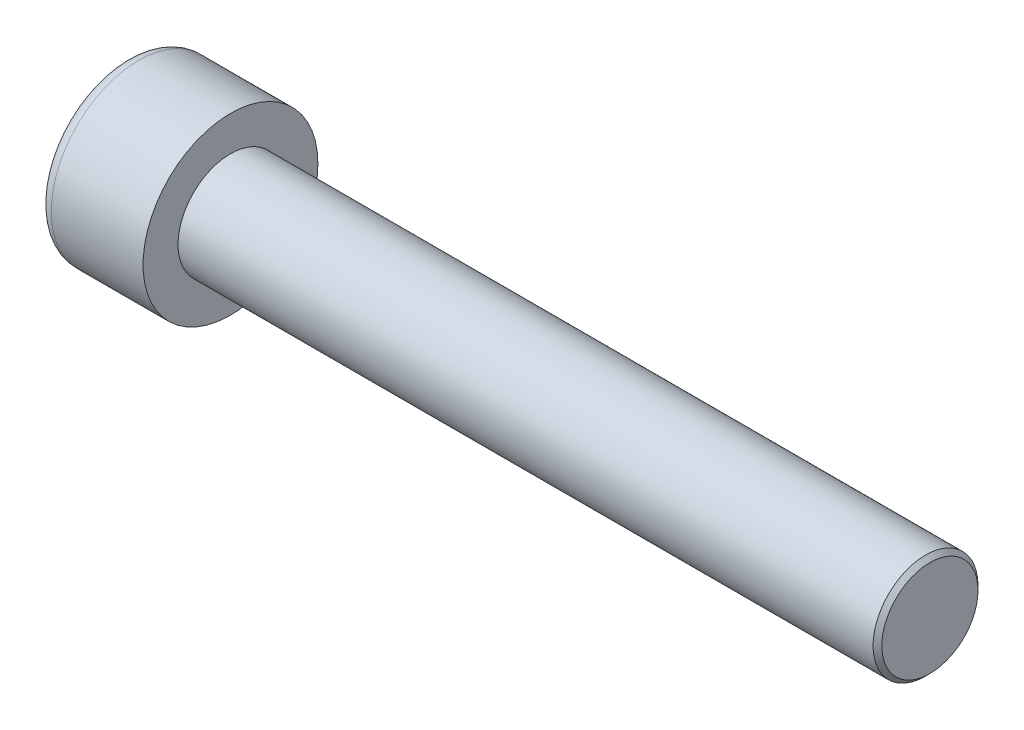
from build123d import *

# Parameters (mm, degrees)
SKETCH1_R           = 5
BASEHEAD_DEPTH      = 6
SKETCH2_R           = 3
BASEBODY_DEPTH      = 40
HEXAGONSOCKET_DEPTH = 3
TOPFILLET_R         = 0.75
CHAMFER1_SIZE       = 0.25


with BuildPart() as part:
    # Sketch1 → BaseHead (new body)
    with BuildSketch(Plane(origin=(0, 0, 0), x_dir=(0, 0, -1), z_dir=(1, 0, 0))):
        Circle(SKETCH1_R)
    extrude(amount=BASEHEAD_DEPTH)

    # Sketch2 → BaseBody (add)
    with BuildSketch(Plane(origin=(6, 0, 0), x_dir=(0, 0, -1), z_dir=(1, 0, 0))):
        Circle(SKETCH2_R)
    extrude(amount=BASEBODY_DEPTH)

    # Sketch3 → HexagonSocket (cut)
    with BuildSketch(Plane(origin=(0, 0, 0), x_dir=(0, 0, -1), z_dir=(1, 0, 0))):
        Polygon((2.886751346, 0), (1.443375673, 2.5), (-1.443375673, 2.5), (-2.886751346, 0), (-1.443375673, -2.5), (1.443375673, -2.5), align=None)
    extrude(amount=HEXAGONSOCKET_DEPTH, mode=Mode.SUBTRACT)

    # Sketch4 → Cut-Revolve1 (revolve, cut)
    with BuildSketch(Plane(origin=(-4.19613823, 0.75, 0), x_dir=(-1, 0, 0), z_dir=(0, 0, 1))):
        Polygon((-7.19613823, 3.25), (-8.639513903, 0.75), (-7.19613823, 0.75), align=None)
    revolve(axis=Axis((0.838992387, 0, 0), (-1, 0, 0)), mode=Mode.SUBTRACT)

    # TopFillet
    topfillet_edges = [part.edges().sort_by_distance(p)[0] for p in [
        (0, 0, 5),
    ]]
    fillet(topfillet_edges, radius=TOPFILLET_R)

    # Chamfer1
    chamfer1_edges = [part.edges().sort_by_distance(p)[0] for p in [
        (46, 0, 3),
    ]]
    chamfer(chamfer1_edges, length=CHAMFER1_SIZE)


solid = part.part
